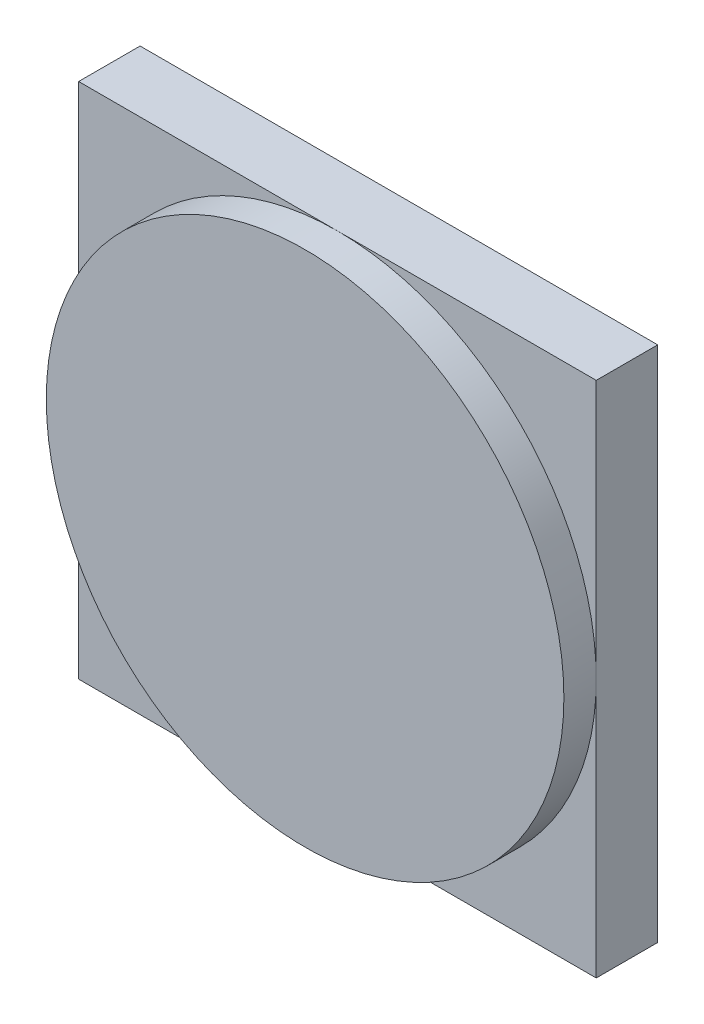
from build123d import *

# Parameters (mm, degrees)
SKETCH1_R           = 40
BOSS_EXTRUDE1_DEPTH = 5
SKETCH2_W           = 80
SKETCH2_H           = 80
BOSS_EXTRUDE2_DEPTH = 9.5


with BuildPart() as part:
    # Sketch1 → Boss-Extrude1 (new body)
    with BuildSketch(Plane(origin=(0, 0, 0), x_dir=(0, 1, 0), z_dir=(0, 0, 1))):
        Circle(SKETCH1_R)
    extrude(amount=BOSS_EXTRUDE1_DEPTH)

    # Sketch2 → Boss-Extrude2 (add)
    with BuildSketch(Plane(origin=(0, 0, 0), x_dir=(1, 0, 0), z_dir=(0, 0, -1))):
        Rectangle(SKETCH2_W, SKETCH2_H)
    extrude(amount=BOSS_EXTRUDE2_DEPTH)


solid = part.part
